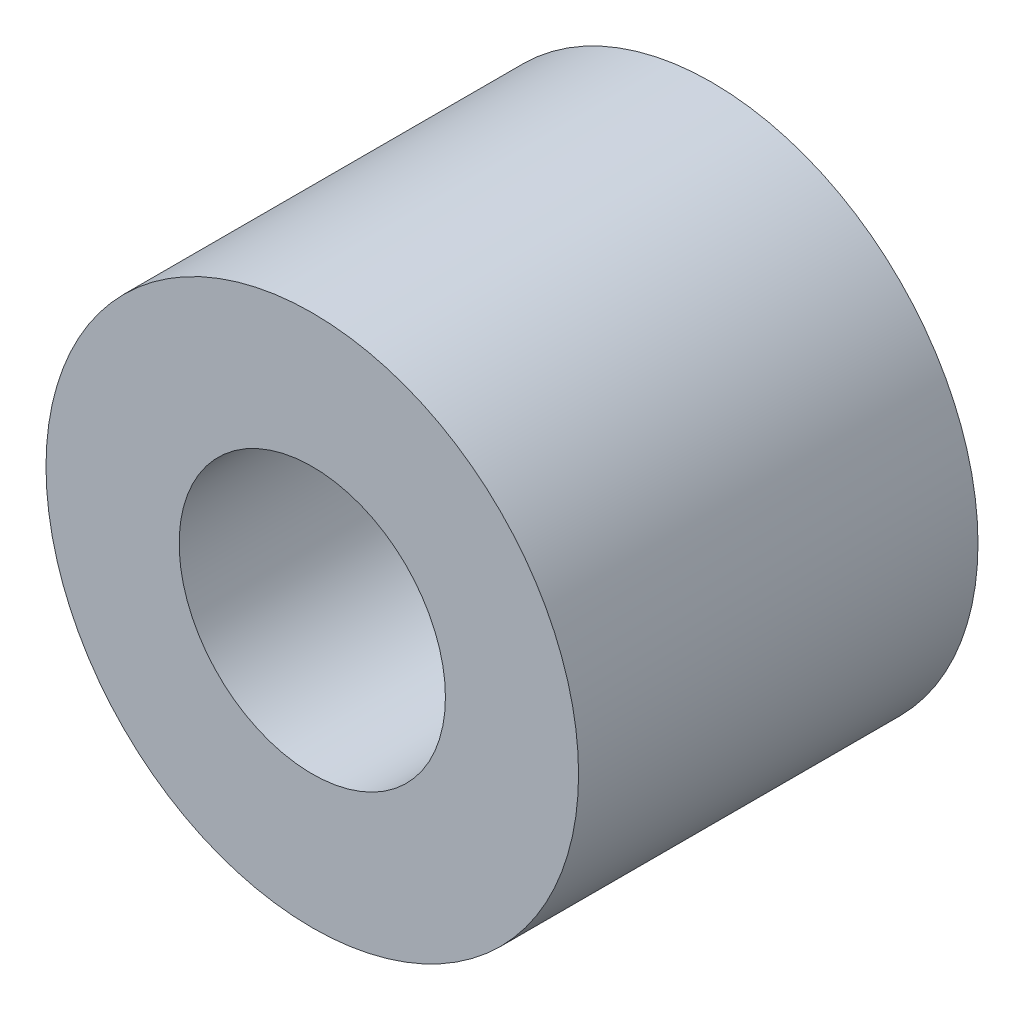
from build123d import *

# Parameters (mm, degrees)
SKETCH1_R           = 10
SKETCH1_R_2         = 5
BOSS_EXTRUDE1_DEPTH = 15


with BuildPart() as part:
    # Sketch1 → Boss-Extrude1 (new body)
    with BuildSketch(Plane.XY):
        Circle(SKETCH1_R)
        Circle(SKETCH1_R_2, mode=Mode.SUBTRACT)
    extrude(amount=BOSS_EXTRUDE1_DEPTH)


solid = part.part
